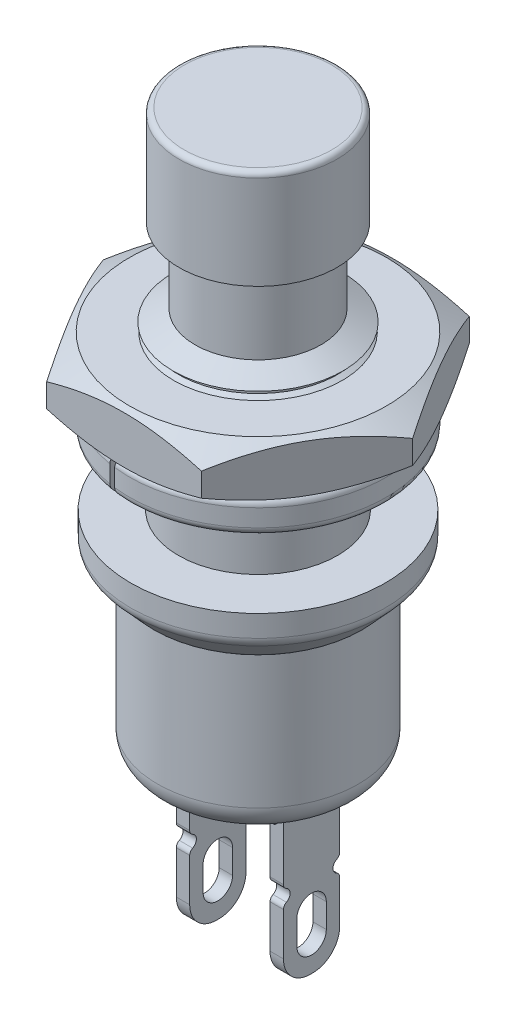
from build123d import *

# Parameters (mm, degrees)
SKETCH3_R                = 3.75
BOSS_EXTRUDE1_DEPTH      = 6
FILLET1_R                = 1
LPATTERN1_COUNT          = 10
LPATTERN1_PITCH          = 0.5
SKETCH6_R                = 1.75
CUT_EXTRUDE1_DEPTH       = 10
SKETCH7_W                = 0.5
SKETCH7_H                = 2.75
BOSS_EXTRUDE2_DEPTH      = 0.5
SKETCH8_W                = 0.5
SKETCH8_H                = 2.1
BOSS_EXTRUDE3_DEPTH      = 5.5
SKETCH9_R                = 0.25
CUT_EXTRUDE2_DEPTH       = 4
CUT_EXTRUDE3_DEPTH       = 4
FILLET2_R                = 0.2
FILLET3_R                = 1
SKETCH12_R               = 4.8
SKETCH12_R_2             = 3.55
BOSS_EXTRUDE4_DEPTH      = 1.25
CUT_EXTRUDE4_DEPTH       = 1.25
FILLET5_R                = 0.3
SKETCH14_R               = 3.15
BOSS_EXTRUDE5_DEPTH      = 2
SKETCH_19_5_DOWN_21_UP_W = 0.3
SKETCH_19_5_DOWN_21_UP_H = 8


with BuildPart() as part:
    # Sketch1 → Revolve1 (revolve)
    with BuildSketch(Plane.XY):
        with BuildLine():
            Line((0, 0), (0, -2))
            Line((0, -2), (3.75, -2))
            ThreePointArc((3.75, -2), (3.830780411, -1.982960447), (3.897796201, -1.934745252))
            Line((3.897796201, -1.934745252), (4.619490503, -1.143150186))
            ThreePointArc((4.619490503, -1.143150186), (4.716232373, -0.986917547), (4.75, -0.806287057))
            Line((4.75, -0.806287057), (4.75, 0))
            Line((4.75, 0), (0, 0))
        make_face()
    revolve(axis=Axis((0, 0, 0), (0, -1, 0)))

    # Sketch3 → Boss-Extrude1 (add)
    with BuildSketch(Plane.XZ.offset(2)):
        Circle(SKETCH3_R)
    extrude(amount=BOSS_EXTRUDE1_DEPTH)

    # Fillet1
    fillet1_edges = [part.edges().sort_by_distance(p)[0] for p in [
        (-3.75, -8, 0),
    ]]
    fillet(fillet1_edges, radius=FILLET1_R)

    # Sketch4 → Revolve2 (revolve)
    with BuildSketch(Plane.XY):
        Polygon((0, 0), (0, 10.5), (2.35, 10.5), (2.35, 6.5), (3.3, 6), (3.3, 1.4), (2.97, 1.4), (2.97, 0), align=None)
    revolve(axis=Axis((0, 0, 0), (0, -1, 0)))

    # Sketch5 → Cut-Revolve1 (revolve, cut)
    with BuildSketch(Plane.XY):
        Polygon((3.816410162, 1.65), (3.816410162, 1.15), (3.316410162, 1.15), (2.97, 1.35), (2.97, 1.45), (3.316410162, 1.65), align=None)
    cut_revolve1 = revolve(axis=Axis((0, 0, 0), (0, 1, 0)), mode=Mode.SUBTRACT)

    # LPattern1: Cut-Revolve1 ×10
    with Locations(*[(0, i * LPATTERN1_PITCH, 0) for i in range(1, LPATTERN1_COUNT)]):
        add(cut_revolve1, mode=Mode.SUBTRACT)

    # Sketch6 → Cut-Extrude1 (cut)
    with BuildSketch(Plane(origin=(0, 10.5, 0), x_dir=(1, 0, 0), z_dir=(0, 1, 0))):
        Circle(SKETCH6_R)
    extrude(amount=-CUT_EXTRUDE1_DEPTH, mode=Mode.SUBTRACT)

    # Sketch7 → Boss-Extrude2 (add)
    with BuildSketch(Plane.XZ.offset(8)):
        with Locations((1.75, 0)):
            Rectangle(SKETCH7_W, SKETCH7_H)
        with Locations((-1.75, 0)):
            Rectangle(SKETCH7_W, SKETCH7_H)
    extrude(amount=BOSS_EXTRUDE2_DEPTH)

    # Sketch8 → Boss-Extrude3 (add)
    with BuildSketch(Plane.XZ.offset(8.5)):
        with Locations((-1.75, 0)):
            Rectangle(SKETCH8_W, SKETCH8_H)
        with Locations((1.75, 0)):
            Rectangle(SKETCH8_W, SKETCH8_H)
    extrude(amount=BOSS_EXTRUDE3_DEPTH)

    # Sketch9 → Cut-Extrude2 (cut)
    with BuildSketch(Plane(origin=(2, 0, 0), x_dir=(0, 0, -1), z_dir=(1, 0, 0))):
        with Locations((-1.05, -11)):
            Circle(SKETCH9_R)
        with Locations((1.05, -11)):
            Circle(SKETCH9_R)
    extrude(amount=-CUT_EXTRUDE2_DEPTH, mode=Mode.SUBTRACT)

    # Sketch10 → Cut-Extrude3 (cut)
    with BuildSketch(Plane(origin=(2, 0, 0), x_dir=(0, 0, -1), z_dir=(1, 0, 0))):
        with BuildLine():
            Line((0.55, -11.95), (0.55, -12.85))
            ThreePointArc((0.55, -12.85), (0, -13.4), (-0.55, -12.85))
            Line((-0.55, -12.85), (-0.55, -11.95))
            ThreePointArc((-0.55, -11.95), (0, -11.4), (0.55, -11.95))
        make_face()
    extrude(amount=-CUT_EXTRUDE3_DEPTH, mode=Mode.SUBTRACT)

    # Fillet2
    fillet2_edges = [part.edges().sort_by_distance(p)[0] for p in [
        (1.75, -10.75, -1.05),
        (1.75, -11.25, -1.05),
        (1.75, -11.25, 1.05),
        (1.75, -10.75, 1.05),
        (-1.75, -11.25, -1.05),
        (-1.75, -10.75, -1.05),
        (-1.75, -10.75, 1.05),
        (-1.75, -11.25, 1.05),
    ]]
    fillet(fillet2_edges, radius=FILLET2_R)

    # Fillet3
    fillet3_edges = [part.edges().sort_by_distance(p)[0] for p in [
        (-1.75, -14, -1.05),
        (-1.75, -14, 1.05),
        (1.75, -14, 1.05),
        (1.75, -14, -1.05),
    ]]
    fillet(fillet3_edges, radius=FILLET3_R)

    # Sketch19 → Real-World Weight Adjustment (revolve, cut)
    with BuildSketch(Plane.XY):
        with BuildLine():
            Line((0, 5.2), (0, -7.8))
            Line((0, -7.8), (2.1, -7.8))
            ThreePointArc((2.1, -7.8), (2.807106781, -7.507106781), (3.1, -6.8))
            Line((3.1, -6.8), (3.1, -2.2))
            Line((3.1, -2.2), (4.2, -1))
            Line((4.2, -1), (4.2, -0.3))
            Line((4.2, -0.3), (2.5, -0.3))
            Line((2.5, -0.3), (2.5, 5.2))
            Line((2.5, 5.2), (0, 5.2))
        make_face()
    revolve(axis=Axis((0, -7.8, 0), (0, -1, 0)), mode=Mode.SUBTRACT)


with BuildPart() as body_2:
    # Sketch12 → Boss-Extrude4 (new body)
    with BuildSketch(Plane(origin=(0, 2.5, 0), x_dir=(1, 0, 0), z_dir=(0, 1, 0))):
        Circle(SKETCH12_R)
        Circle(SKETCH12_R_2, mode=Mode.SUBTRACT)
    extrude(amount=BOSS_EXTRUDE4_DEPTH)

    # Sketch13 → Cut-Extrude4 (cut)
    with BuildSketch(Plane(origin=(0, 3.75, 0), x_dir=(1, 0, 0), z_dir=(0, 1, 0))):
        with BuildLine():
            Line((-0.114405452, -3.548156055), (-0.798539226, -4.733110511))
            ThreePointArc((-0.798539226, -4.733110511), (-0.69220472, -4.749826589), (-0.585522116, -4.764154054))
            Line((-0.585522116, -4.764154054), (0.116575435, -3.548085423))
            ThreePointArc((0.116575435, -3.548085423), (0.001085566, -3.549999834), (-0.114405452, -3.548156055))
        make_face()
    extrude(amount=-CUT_EXTRUDE4_DEPTH, mode=Mode.SUBTRACT)

    # Fillet5
    fillet5_edges = [body_2.edges().sort_by_distance(p)[0] for p in [
        (-3.098952381, 3.75, -3.665582374),
        (-3.098952381, 2.5, -3.665582374),
        (-2.469449397, 2.5, -2.550356774),
        (-2.469449397, 3.75, -2.550356774),
    ]]
    fillet(fillet5_edges, radius=FILLET5_R)


with BuildPart() as body_3:
    # Sketch14 → Boss-Extrude5 (new body)
    with BuildSketch(Plane(origin=(0, 3.75, 0), x_dir=(1, 0, 0), z_dir=(0, 1, 0))):
        Polygon((5.773502692, 0), (2.886751346, 5), (-2.886751346, 5), (-5.773502692, 0), (-2.886751346, -5), (2.886751346, -5), align=None)
        Circle(SKETCH14_R, mode=Mode.SUBTRACT)
    extrude(amount=BOSS_EXTRUDE5_DEPTH)

    # Sketch15 → Cut-Revolve2 (revolve, cut)
    with BuildSketch(Plane.XY):
        Polygon((4.8, 5.75), (5.773502692, 5.75), (5.773502692, 5.187947959), align=None)
        Polygon((4.8, 3.75), (5.773502692, 3.75), (5.773502692, 4.312052041), align=None)
    revolve(axis=Axis((0, 3.75, 0), (0, 1, 0)), mode=Mode.SUBTRACT)


with BuildPart() as body_4:
    # Sketch 19.5 Down 21 Up → SWITCH 19.5 Down 21 Up (revolve)
    with BuildSketch(Plane.XY):
        with Locations((1.6, 8)):
            Rectangle(SKETCH_19_5_DOWN_21_UP_W, SKETCH_19_5_DOWN_21_UP_H)
    revolve(axis=Axis((0, 4, 0), (0, 1, 0)))


with BuildPart() as body_5:
    # Sketch21 → Red Cap (revolve)
    with BuildSketch(Plane.XY):
        with BuildLine():
            Line((0, 13), (0, 12))
            Line((0, 12), (2.35, 12))
            Line((2.35, 12), (2.35, 9.3))
            Line((2.35, 9.3), (2.95, 9.3))
            Line((2.95, 9.3), (2.95, 12.8))
            ThreePointArc((2.95, 12.8), (2.891421356, 12.941421356), (2.75, 13))
            Line((2.75, 13), (0, 13))
        make_face()
    revolve(axis=Axis((0, 12, 0), (0, 1, 0)))


solid = Compound([part.part, body_2.part, body_3.part, body_4.part, body_5.part])
